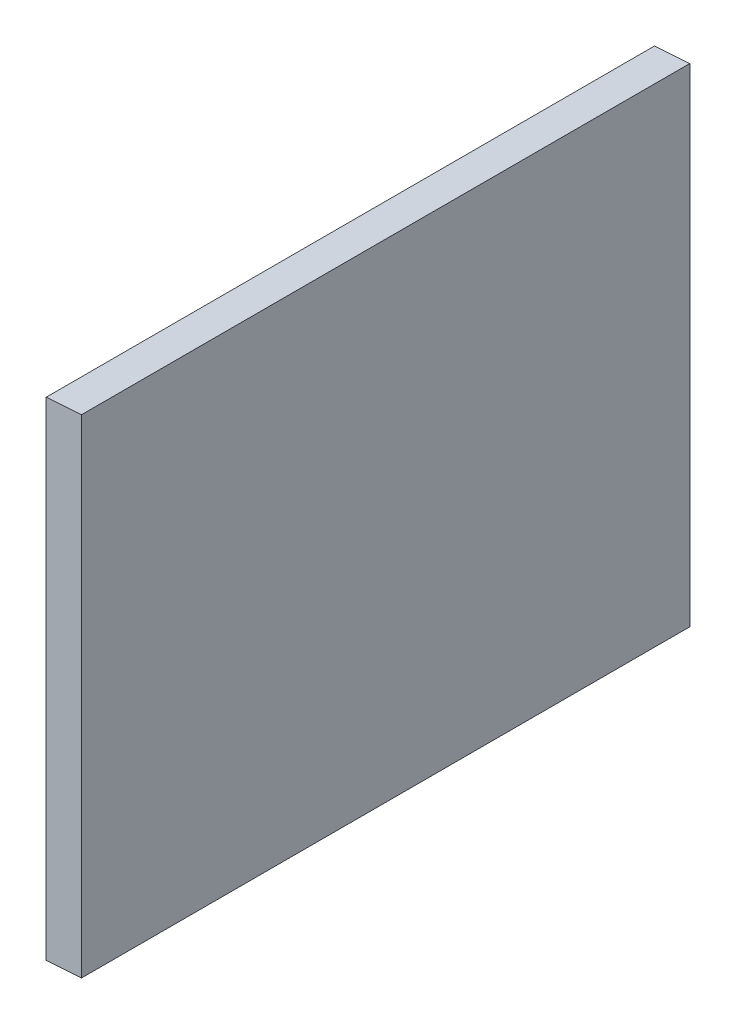
from build123d import *

# Parameters (mm, degrees)
BOSS_EXTRUDE1_DEPTH = 400


with BuildPart() as part:
    # Sketch1 → Boss-Extrude1 (new body)
    with BuildSketch(Plane.XY):
        Polygon((0, 0), (0, 320.8), (-23.2, 319.177697963), (-23.2, -1.622302037), align=None)
    extrude(amount=BOSS_EXTRUDE1_DEPTH)


solid = part.part
